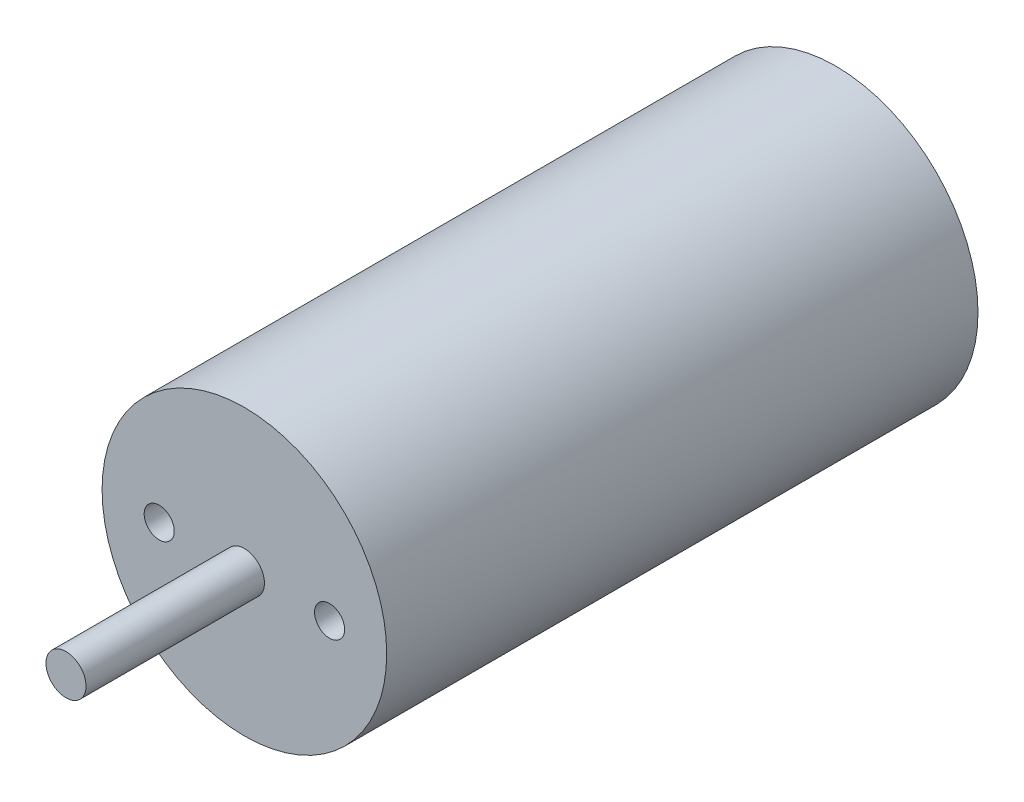
from build123d import *

# Parameters (mm, degrees)
SKETCH1_R           = 14.2
BOSS_EXTRUDE1_DEPTH = 59
SKETCH2_R           = 2
BOSS_EXTRUDE2_DEPTH = 17.8
SKETCH3_R           = 1.5
CUT_EXTRUDE1_DEPTH  = 4.3942


with BuildPart() as part:
    # Sketch1 → Boss-Extrude1 (new body)
    with BuildSketch(Plane.XY):
        Circle(SKETCH1_R)
    extrude(amount=BOSS_EXTRUDE1_DEPTH)

    # Sketch2 → Boss-Extrude2 (add)
    with BuildSketch(Plane.XY.offset(59)):
        Circle(SKETCH2_R)
    extrude(amount=BOSS_EXTRUDE2_DEPTH)

    # Sketch3 → Cut-Extrude1 (cut)
    with BuildSketch(Plane.XY.offset(59)):
        with Locations((-8.5, 0)):
            Circle(SKETCH3_R)
        with Locations((8.5, 0)):
            Circle(SKETCH3_R)
    extrude(amount=-CUT_EXTRUDE1_DEPTH, mode=Mode.SUBTRACT)


solid = part.part
